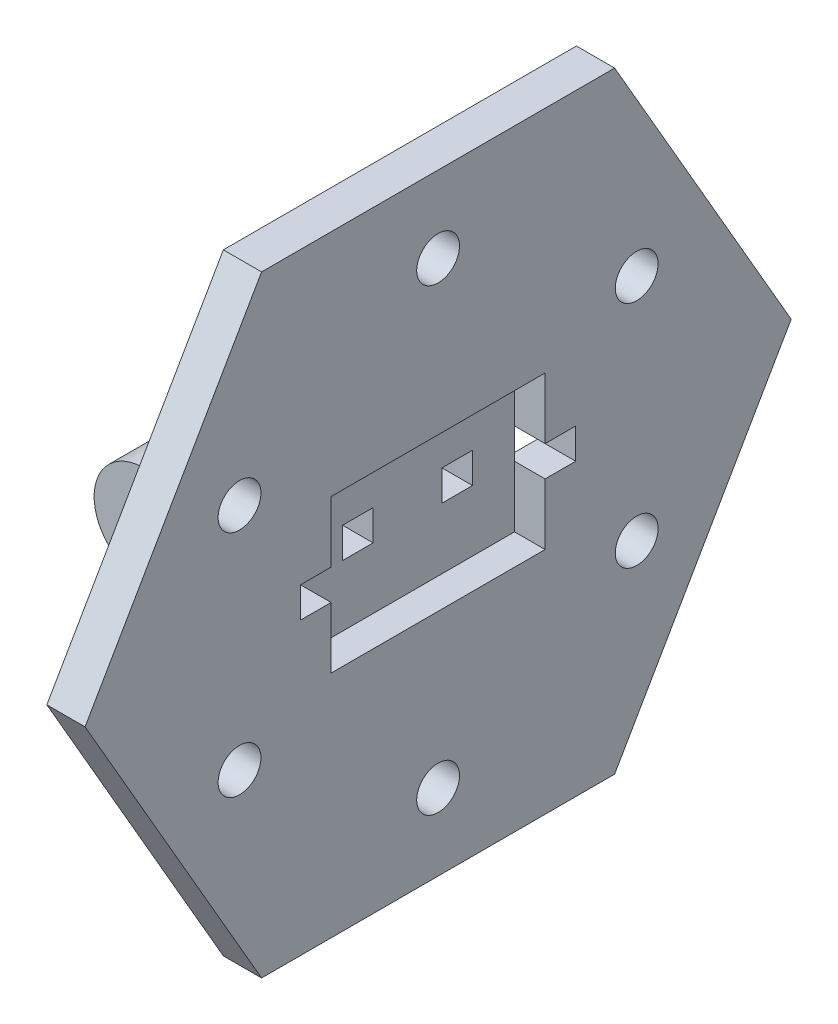
from build123d import *

# Parameters (mm, degrees)
SKETCH_1_R          = 3.25
EXTRUDE_1_DEPTH     = 19.5
SKETCH_2_W          = 14
SKETCH_2_H          = 20
EXTRUDE_2_DEPTH     = 2
EXTRUDE_3_DEPTH     = 14
FILLET_1_R          = 2
EXTRUDE_4_DEPTH     = 2.5
SKETCH_6_W          = 2
SKETCH_6_H          = 2
CUT_EXTRUDE_1_DEPTH = 13.75
SKETCH_7_W          = 14
SKETCH_7_H          = 10
CUT_EXTRUDE_2_DEPTH = 2
SKETCH_8_W          = 2
SKETCH_8_H          = 2
CUT_EXTRUDE_3_DEPTH = 2.5
SKETCH_14_R         = 1.4
CUT_EXTRUDE_4_DEPTH = 2.5


with BuildPart() as part:
    # Sketch 1 → Extrude 1 (new body)
    with BuildSketch(Plane.XY):
        Circle(SKETCH_1_R)
    extrude(amount=EXTRUDE_1_DEPTH)



with BuildPart() as body_2:
    # Sketch 2 → Extrude 2 (new body)
    with BuildSketch(Plane(origin=(5, 0, 0), x_dir=(0, 0, -1), z_dir=(1, 0, 0))):
        with Locations((-9.75, 0)):
            Rectangle(SKETCH_2_W, SKETCH_2_H)
    extrude(amount=EXTRUDE_2_DEPTH)


with BuildPart() as part_1:
    add(part.part)

    add(body_2.part)  # Extrude 3 merges body 2
    # Sketch 3 → Extrude 3 (add)
    with BuildSketch(Plane(origin=(0, 0, 2.75), x_dir=(-1, 0, 0), z_dir=(0, 0, -1))):
        Polygon((0, 0), (-5, 4.5), (-5, -4.5), align=None)
    extrude(amount=-EXTRUDE_3_DEPTH)

    # Fillet 1
    fillet_1_edges = [part_1.edges().sort_by_distance(p)[0] for p in [
        (2.415705975, 2.174135378, 9.75),
        (2.415705975, -2.174135378, 9.75),
        (5, 4.5, 9.75),
        (5, -4.5, 9.75),
    ]]
    fillet(fillet_1_edges, radius=FILLET_1_R)

    # Sketch 5 → Extrude 4 (add)
    with BuildSketch(Plane(origin=(7, 0, 0), x_dir=(0, 0, -1), z_dir=(1, 0, 0))):
        Polygon((-21.297005384, 20), (-32.844010768, 0), (-21.297005384, -20), (1.797005384, -20), (13.344010768, 0), (1.797005384, 20), align=None)
    extrude(amount=EXTRUDE_4_DEPTH)

    # Sketch 6 → Cut-Extrude 1 (cut, through all)
    with BuildSketch(Plane(origin=(9.5, 0, 0), x_dir=(0, 0, -1), z_dir=(1, 0, 0))):
        with Locations((-13, 0)):
            Rectangle(SKETCH_6_W, SKETCH_6_H)
        with Locations((-6.5, 0)):
            Rectangle(SKETCH_6_W, SKETCH_6_H)
    extrude(amount=-CUT_EXTRUDE_1_DEPTH, mode=Mode.SUBTRACT)

    # Sketch 7 → Cut-Extrude 2 (cut)
    with BuildSketch(Plane(origin=(9.5, 0, 0), x_dir=(0, 0, -1), z_dir=(1, 0, 0))):
        with Locations((-9.75, 0)):
            Rectangle(SKETCH_7_W, SKETCH_7_H)
    extrude(amount=-CUT_EXTRUDE_2_DEPTH, mode=Mode.SUBTRACT)

    # Sketch 8 → Cut-Extrude 3 (cut)
    with BuildSketch(Plane(origin=(9.5, 0, 0), x_dir=(0, 0, -1), z_dir=(1, 0, 0))):
        with Locations((-17.75, 0)):
            Rectangle(SKETCH_8_W, SKETCH_8_H)
        with Locations((-1.75, 0)):
            Rectangle(SKETCH_8_W, SKETCH_8_H)
    extrude(amount=-CUT_EXTRUDE_3_DEPTH, mode=Mode.SUBTRACT)

    # Sketch 14 → Cut-Extrude 4 (cut)
    with BuildSketch(Plane(origin=(9.5, 0, 0), x_dir=(0, 0, -1), z_dir=(1, 0, 0))):
        with Locations((-9.75, 15)):
            Circle(SKETCH_14_R)
        with Locations((3.240381057, 7.5)):
            Circle(SKETCH_14_R)
        with Locations((3.240381057, -7.5)):
            Circle(SKETCH_14_R)
        with Locations((-9.75, -15)):
            Circle(SKETCH_14_R)
        with Locations((-22.740381057, -7.5)):
            Circle(SKETCH_14_R)
        with Locations((-22.740381057, 7.5)):
            Circle(SKETCH_14_R)
    extrude(amount=-CUT_EXTRUDE_4_DEPTH, mode=Mode.SUBTRACT)


solid = part_1.part
